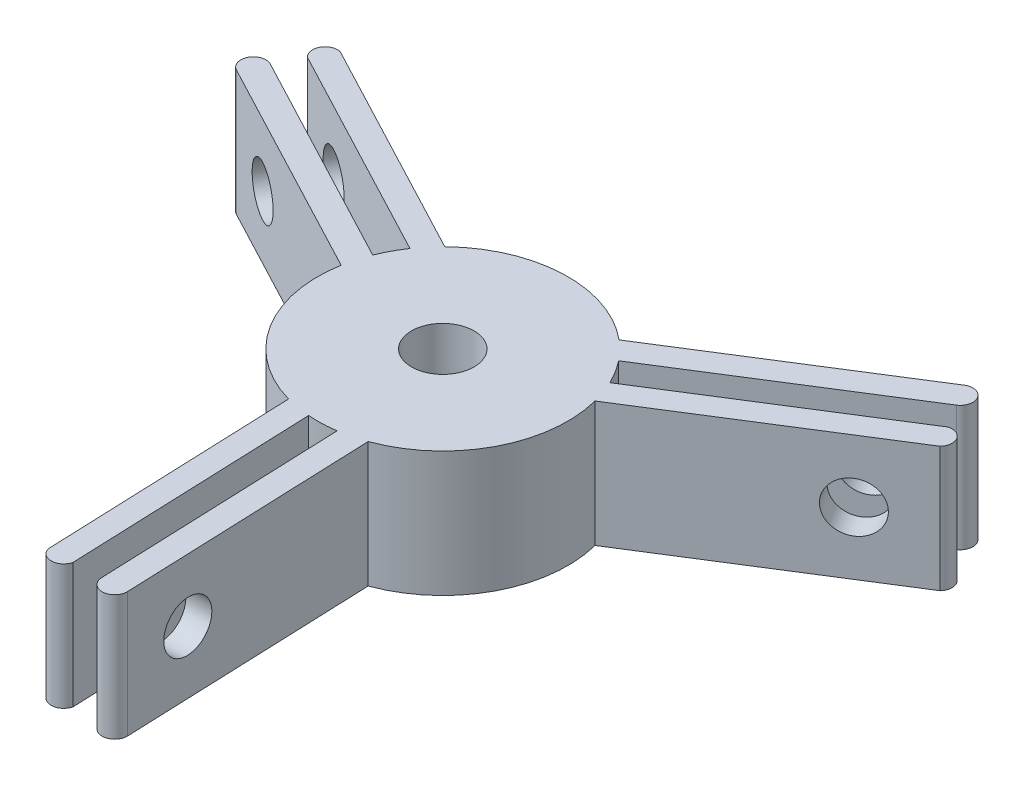
from build123d import *

# Parameters (mm, degrees)
SKETCH1_R           = 2.5
BOSS_EXTRUDE1_DEPTH = 10
SKETCH2_R           = 2
CUT_EXTRUDE1_DEPTH  = 10
CIRPATTERN1_COUNT   = 3


with BuildPart() as part:
    # Sketch1 → Boss-Extrude1 (new body)
    with BuildSketch(Plane(origin=(0, 0, 0), x_dir=(1, 0, 0), z_dir=(0, 1, 0))):
        with BuildLine():
            Line((3.42943918, -9.393558799), (4.197898245, -29.378790113))
            ThreePointArc((4.197898245, -29.378790113), (3.237059632, -30.416474632), (2.199375114, -29.455636019))
            Line((2.199375114, -29.455636019), (1.447231615, -9.894721858))
            ThreePointArc((1.447231615, -9.894721858), (0.350023332, -9.993872306), (-0.751433173, -9.971727442))
            Line((-0.751433173, -9.971727442), (0.000999669, -29.540166516))
            ThreePointArc((0.000999669, -29.540166516), (-0.935779597, -30.318112399), (-1.929530696, -29.614398009))
            Line((-1.929530696, -29.614398009), (-2.697989761, -9.629166695))
            ThreePointArc((-2.697989761, -9.629166695), (-8.461744243, -5.329060364), (-9.849780142, 1.726797949))
            Line((-9.849780142, 1.726797949), (-27.541727692, 11.053908534))
            ThreePointArc((-27.541727692, 11.053908534), (-27.959969541, 12.404861441), (-26.609016634, 12.823103289))
            Line((-26.609016634, 12.823103289), (-9.2926963, 3.694021585))
            ThreePointArc((-9.2926963, 3.694021585), (-8.829958965, 4.693807055), (-8.260052699, 5.636623938))
            Line((-8.260052699, 5.636623938), (-25.58303447, 14.769217519))
            ThreePointArc((-25.58303447, 14.769217519), (-25.788365734, 15.969465103), (-24.682055646, 16.478221605))
            Line((-24.682055646, 16.478221605), (-6.990108095, 7.15111102))
            ThreePointArc((-6.990108095, 7.15111102), (-0.384229532, 9.992615657), (6.420340962, 7.66676085))
            Line((6.420340962, 7.66676085), (23.343829448, 18.324881579))
            ThreePointArc((23.343829448, 18.324881579), (24.722909908, 18.011613191), (24.40964152, 16.63253273))
            Line((24.40964152, 16.63253273), (7.845464685, 6.200700273))
            ThreePointArc((7.845464685, 6.200700273), (8.479935633, 5.300065251), (9.011485871, 4.335103505))
            Line((9.011485871, 4.335103505), (25.582034801, 14.770948997))
            ThreePointArc((25.582034801, 14.770948997), (26.724145331, 14.348647296), (26.611586342, 13.136176404))
            Line((26.611586342, 13.136176404), (9.688097856, 2.478055676))
            ThreePointArc((9.688097856, 2.478055676), (8.845973775, -4.663555293), (3.42943918, -9.393558799))
        make_face()
        Circle(SKETCH1_R, mode=Mode.SUBTRACT)
    extrude(amount=BOSS_EXTRUDE1_DEPTH)

    # Sketch2 → Cut-Extrude1 (cut)
    with BuildSketch(Plane(origin=(3.063714471, 0, -0.117803948), x_dir=(-0.038422953, 0, -0.999261566), z_dir=(0.999261566, 0, -0.038422953))):
        with Locations((-24.518391454, 5)):
            Circle(SKETCH2_R)
    cut_extrude1 = extrude(amount=-CUT_EXTRUDE1_DEPTH, mode=Mode.SUBTRACT)

    # CirPattern1: Cut-Extrude1 ×3 about axis
    cirpattern1_axis = Axis((0, 10, 0), (0, -1, 0))
    for i in range(1, CIRPATTERN1_COUNT):
        add(cut_extrude1.rotate(cirpattern1_axis, i * 360 / CIRPATTERN1_COUNT), mode=Mode.SUBTRACT)


solid = part.part
